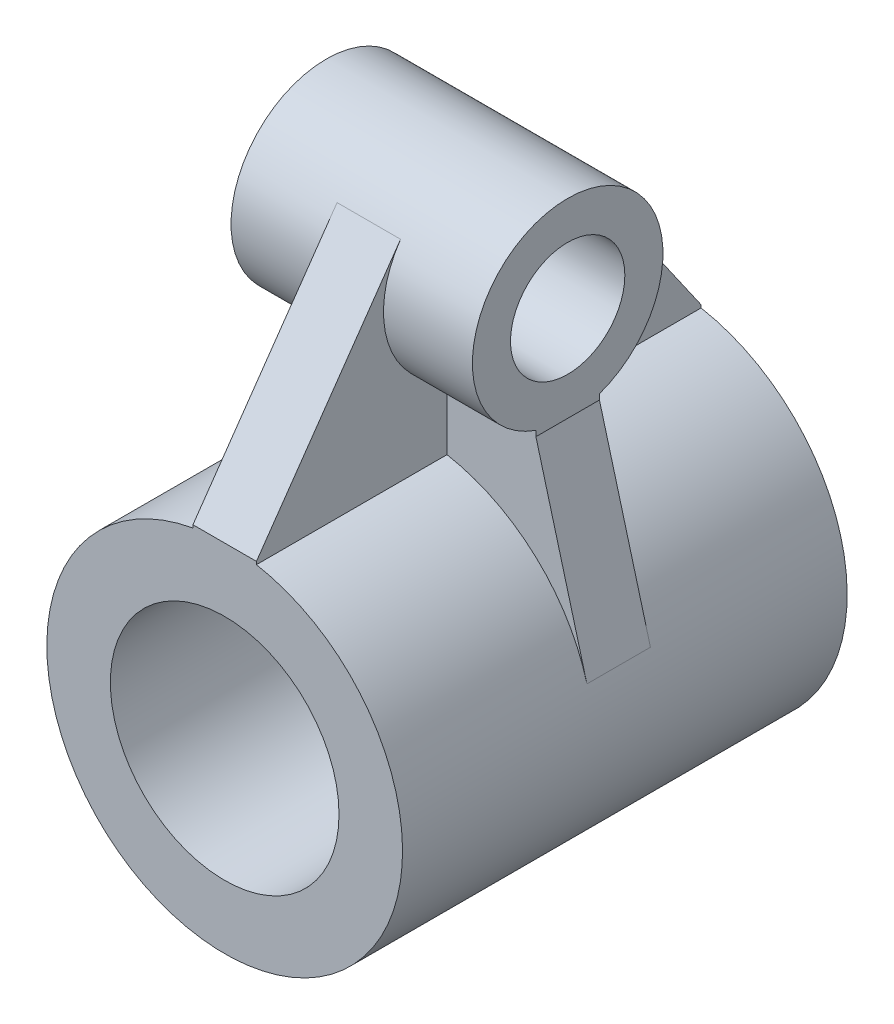
from build123d import *

# Parameters (mm, degrees)
SKETCH1_R           = 14
SKETCH1_R_2         = 9
BOSS_EXTRUDE1_DEPTH = 17.5
SKETCH7_R           = 7.5
SKETCH7_R_2         = 4.5
BOSS_EXTRUDE5_DEPTH = 9.5
BOSS_EXTRUDE7_DEPTH = 2.5
BOSS_EXTRUDE8_DEPTH = 2.5


with BuildPart() as part:
    # Sketch1 → Boss-Extrude1 (new body, symmetric)
    with BuildSketch(Plane.XY):
        Circle(SKETCH1_R)
        Circle(SKETCH1_R_2, mode=Mode.SUBTRACT)
    extrude(amount=BOSS_EXTRUDE1_DEPTH, both=True)



with BuildPart() as body_2:
    # Sketch7 → Boss-Extrude5 (new body, symmetric)
    with BuildSketch(Plane(origin=(0, 0, 0), x_dir=(0, 0, -1), z_dir=(1, 0, 0))):
        with Locations((0, 26)):
            Circle(SKETCH7_R)
        with Locations((0, 26)):
            Circle(SKETCH7_R_2, mode=Mode.SUBTRACT)
    extrude(amount=BOSS_EXTRUDE5_DEPTH, both=True)


with BuildPart() as part_1:
    add(part.part)

    add(body_2.part)  # Boss-Extrude7 merges body 2
    # Sketch8 → Boss-Extrude7 (add, symmetric)
    with BuildSketch(Plane(origin=(0, 0, 0), x_dir=(0, 0, -1), z_dir=(1, 0, 0))):
        with BuildLine():
            Line((-17.5, 14), (-6.153967777, 30.287036342))
            ThreePointArc((-6.153967777, 30.287036342), (0, 18.5), (6.153967777, 30.287036342))
            Line((6.153967777, 30.287036342), (17.5, 14))
            Line((17.5, 14), (17.5, 9))
            Line((17.5, 9), (-17.5, 9))
            Line((-17.5, 9), (-17.5, 14))
        make_face()
    extrude(amount=BOSS_EXTRUDE7_DEPTH, both=True)

    # Sketch9 → Boss-Extrude8 (add, symmetric)
    with BuildSketch(Plane.XY):
        with BuildLine():
            Line((9.5, 18.5), (9.5, 21.5))
            Line((9.5, 21.5), (-9.5, 21.5))
            Line((-9.5, 21.5), (-9.5, 18.5))
            Line((-9.5, 18.5), (-13.514557534, 3.654686672))
            ThreePointArc((-13.514557534, 3.654686672), (0, 14), (13.514557534, 3.654686672))
            Line((13.514557534, 3.654686672), (9.5, 18.5))
        make_face()
    extrude(amount=BOSS_EXTRUDE8_DEPTH, both=True)


solid = part_1.part
